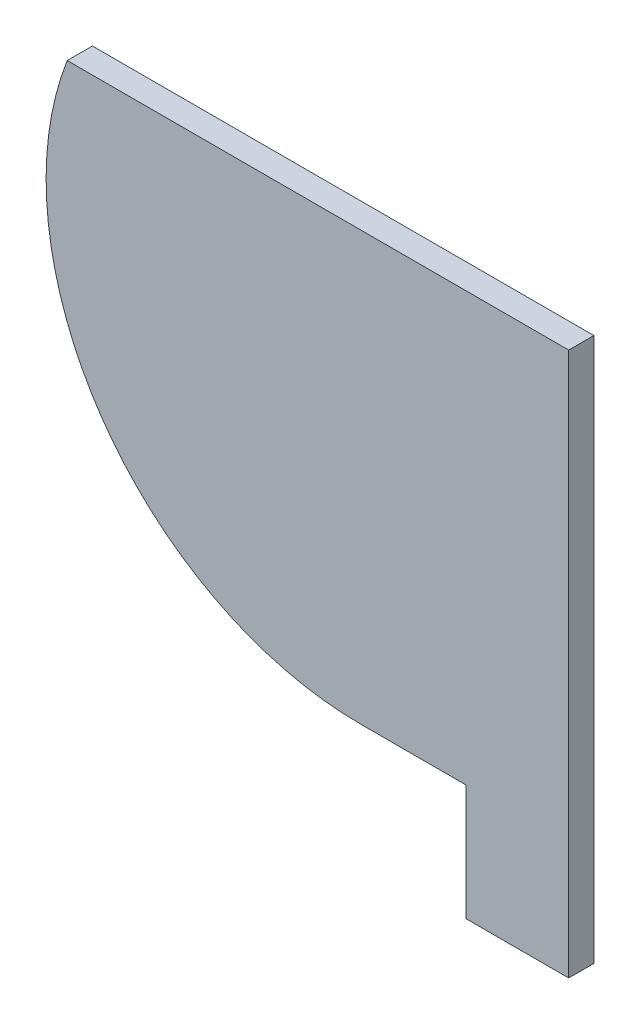
from build123d import *

# Parameters (mm, degrees)
BOSS_EXTRUDE1_DEPTH = 5
SKETCH2_W           = 20.380182207
SKETCH2_H           = 23
BOSS_EXTRUDE2_DEPTH = 5


with BuildPart() as part:
    # Sketch1 → Boss-Extrude1 (new body)
    with BuildSketch(Plane.XY):
        with BuildLine():
            Line((0, 0), (0, -85))
            Line((0, -85), (-41.280574715, -85))
            ThreePointArc((-41.280574715, -85), (-92.819395035, -57.855339059), (-99.590093663, 0))
            Line((-99.590093663, 0), (0, 0))
        make_face()
    extrude(amount=BOSS_EXTRUDE1_DEPTH)

    # Sketch2 → Boss-Extrude2 (add)
    with BuildSketch(Plane.XY.offset(5)):
        with Locations((-10.190091104, -96.5)):
            Rectangle(SKETCH2_W, SKETCH2_H)
    extrude(amount=-BOSS_EXTRUDE2_DEPTH)


solid = part.part
